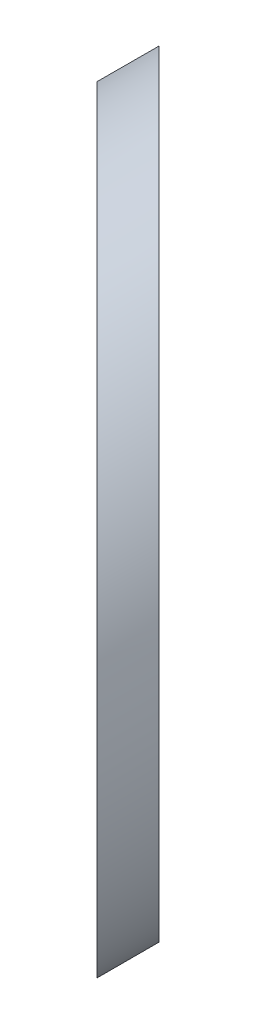
from build123d import *

# Parameters (mm, degrees)
SKETCH_1_R          = 6.25
EXTRUDE_1_DEPTH     = 61
CUT_EXTRUDE_1_DEPTH = 30.5


with BuildPart() as part:
    # 草图1 → 凸台-拉伸1 (new body)
    with BuildSketch(Plane.XY):
        Circle(SKETCH_1_R)
    extrude(amount=EXTRUDE_1_DEPTH)

    # 草图2 → 切除-拉伸1 (cut, symmetric)
    with BuildSketch(Plane(origin=(0, 0, 0), x_dir=(1, 0, 0), z_dir=(0, 1, 0))):
        Polygon((-39.378340461, 21.344490989), (32.946331, -50.980180473), (32.946331, 3.705336734), align=None)
        Polygon((-40.085447243, 20.637384208), (32.239224219, -51.687287254), (29.858688562, -63.951978102), (-29.50048748, -63.951978102), align=None)
    extrude(amount=CUT_EXTRUDE_1_DEPTH, both=True, mode=Mode.SUBTRACT)


solid = part.part
